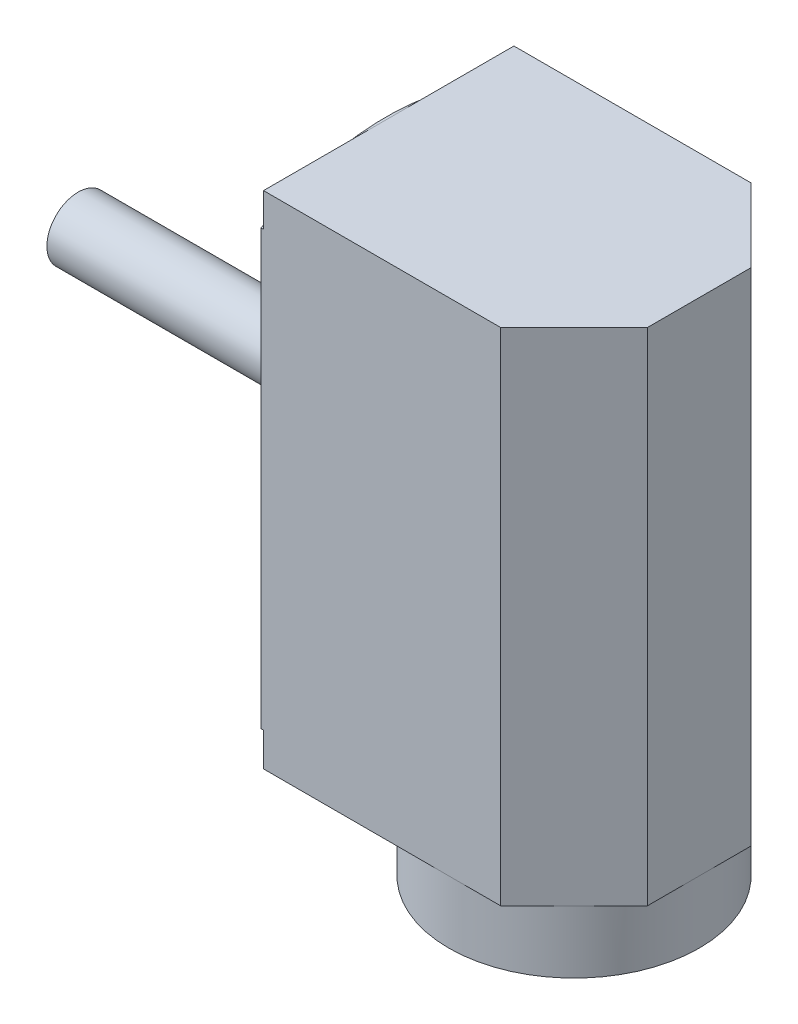
from build123d import *

# Parameters (mm, degrees)
BOSS_EXTRUDE1_DEPTH = 25.4
SKETCH2_R           = 6.35
SKETCH2_R_2         = 4.7625
BOSS_EXTRUDE2_DEPTH = 3.175
SKETCH3_R           = 4.7625
CUT_EXTRUDE1_DEPTH  = 26.19375
SKETCH4_R           = 5.55625
CUT_EXTRUDE2_DEPTH  = 0.254
SKETCH5_R           = 1.5875
BOSS_EXTRUDE3_DEPTH = 15.875
SKETCH6_R           = 0.79375
CUT_EXTRUDE3_DEPTH  = 4.572
CUT_EXTRUDE4_DEPTH  = 0.127


with BuildPart() as part:
    # Sketch1 → Boss-Extrude1 (new body)
    with BuildSketch(Plane(origin=(0, 0, 0), x_dir=(1, 0, 0), z_dir=(0, 1, 0))):
        Polygon((0, -6.35), (0, 6.35), (12.155256121, 6.35), (15.875, 2.630256121), (15.875, -2.630256121), (12.155256121, -6.35), align=None)
    extrude(amount=BOSS_EXTRUDE1_DEPTH)

    # Sketch2 → Boss-Extrude2 (add)
    with BuildSketch(Plane.XZ):
        with Locations((9.525, 0)):
            Circle(SKETCH2_R)
        with Locations((9.525, 0)):
            Circle(SKETCH2_R_2, mode=Mode.SUBTRACT)
    extrude(amount=BOSS_EXTRUDE2_DEPTH)

    # Sketch3 → Cut-Extrude1 (cut)
    with BuildSketch(Plane.XZ.offset(3.175)):
        with Locations((9.525, 0)):
            Circle(SKETCH3_R)
    extrude(amount=-CUT_EXTRUDE1_DEPTH, mode=Mode.SUBTRACT)

    # Sketch4 → Cut-Extrude2 (cut)
    with BuildSketch(Plane.ZY):
        with Locations((0, 12.7)):
            Circle(SKETCH4_R)
    extrude(amount=-CUT_EXTRUDE2_DEPTH, mode=Mode.SUBTRACT)

    # Sketch5 → Boss-Extrude3 (add)
    with BuildSketch(Plane.ZY.offset(-0.254)):
        with Locations((0, 12.7)):
            Circle(SKETCH5_R)
    extrude(amount=BOSS_EXTRUDE3_DEPTH)

    # Sketch6 → Cut-Extrude3 (cut)
    with BuildSketch(Plane.ZY):
        with Locations((0, 22.225)):
            Circle(SKETCH6_R)
    extrude(amount=-CUT_EXTRUDE3_DEPTH, mode=Mode.SUBTRACT)

    # Sketch7 → Cut-Extrude4 (cut)
    with BuildSketch(Plane.ZY):
        with BuildLine():
            ThreePointArc((0, 25.4), (3.287001873, 24.967257994), (6.35, 23.698522628))
            Line((6.35, 23.698522628), (6.35, 25.4))
            Line((6.35, 25.4), (0, 25.4))
        make_face()
        with BuildLine():
            Line((-6.35, 25.4), (-6.35, 23.698522628))
            ThreePointArc((-6.35, 23.698522628), (-3.287001873, 24.967257994), (0, 25.4))
            Line((0, 25.4), (-6.35, 25.4))
        make_face()
        with BuildLine():
            Line((-6.35, 1.701477372), (-6.35, 0))
            Line((-6.35, 0), (0, 0))
            ThreePointArc((0, 0), (-3.287001873, 0.432742006), (-6.35, 1.701477372))
        make_face()
        with BuildLine():
            ThreePointArc((6.35, 1.701477372), (3.287001873, 0.432742006), (0, 0))
            Line((0, 0), (6.35, 0))
            Line((6.35, 0), (6.35, 1.701477372))
        make_face()
    extrude(amount=-CUT_EXTRUDE4_DEPTH, mode=Mode.SUBTRACT)


solid = part.part
